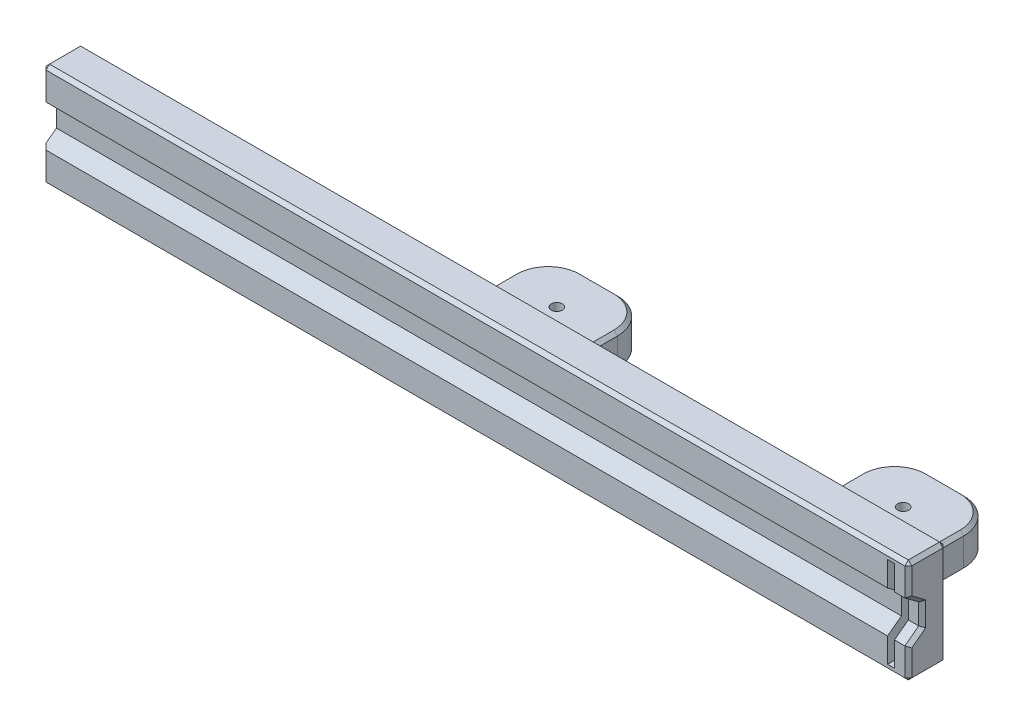
from build123d import *

# Parameters (mm, degrees)
SKETCH_1_W          = 250
SKETCH_1_H          = 30
EXTRUDE_1_DEPTH     = 11
SKETCH_4_W          = 15
SKETCH_4_H          = 5
EXTRUDE_2_DEPTH     = 25
CUT_EXTRUDE_2_DEPTH = 251
CUT_EXTRUDE_3_DEPTH = 21
SKETCH_11_W         = 30
SKETCH_11_H         = 10
EXTRUDE_4_DEPTH     = 25
SKETCH_12_R         = 1.6
CUT_EXTRUDE_5_DEPTH = 21
FILLET_1_R          = 10
SKETCH_13_W         = 2
SKETCH_13_H         = 26.2
CUT_EXTRUDE_6_DEPTH = 37
CHAMFER_1_SIZE      = 1


with BuildPart() as part:
    # 草圖1 → 填料-伸長1 (new body)
    with BuildSketch(Plane.XY):
        with Locations((125, 15)):
            Rectangle(SKETCH_1_W, SKETCH_1_H)
    extrude(amount=EXTRUDE_1_DEPTH)

    # 草圖4 → 填料-伸長2 (add)
    with BuildSketch(Plane(origin=(0, 0, 0), x_dir=(-1, 0, 0), z_dir=(0, 0, -1))):
        with Locations((-132.5, 12.5)):
            Rectangle(SKETCH_4_W, SKETCH_4_H)
        with Locations((-132.5, 17.5)):
            Rectangle(SKETCH_4_W, SKETCH_4_H)
        with Locations((-117.5, 17.5)):
            Rectangle(SKETCH_4_W, SKETCH_4_H)
        with Locations((-117.5, 12.5)):
            Rectangle(SKETCH_4_W, SKETCH_4_H)
    extrude(amount=EXTRUDE_2_DEPTH)

    # 草圖5 → 除料-伸長2 (cut, through all)
    with BuildSketch(Plane(origin=(250, 0, 0), x_dir=(0, 0, -1), z_dir=(1, 0, 0))):
        Polygon((-11, 15), (-7, 15), (-7, 18), (-11, 21), align=None)
        Polygon((-7, 12), (-7, 15), (-11, 15), (-11, 9), align=None)
    extrude(amount=-CUT_EXTRUDE_2_DEPTH, mode=Mode.SUBTRACT)

    # 草圖6 → 除料-伸長3 (cut, through all)
    with BuildSketch(Plane.XZ.offset(-10)):
        with BuildLine():
            ThreePointArc((126.6, -12.5), (126.13137085, -11.36862915), (125, -10.9))
            Line((125, -10.9), (125, -12.5))
            Line((125, -12.5), (126.6, -12.5))
        make_face()
        with BuildLine():
            Line((125, -12.5), (125, -10.9))
            ThreePointArc((125, -10.9), (123.86862915, -11.36862915), (123.4, -12.5))
            Line((123.4, -12.5), (125, -12.5))
        make_face()
        with BuildLine():
            Line((126.6, -12.5), (125, -12.5))
            Line((125, -12.5), (125, -14.1))
            ThreePointArc((125, -14.1), (126.13137085, -13.63137085), (126.6, -12.5))
        make_face()
        with BuildLine():
            Line((125, -14.1), (125, -12.5))
            Line((125, -12.5), (123.4, -12.5))
            ThreePointArc((123.4, -12.5), (123.86862915, -13.63137085), (125, -14.1))
        make_face()
    extrude(amount=-CUT_EXTRUDE_3_DEPTH, mode=Mode.SUBTRACT)

    # 草圖11 → 填料-伸長4 (add)
    with BuildSketch(Plane(origin=(0, 0, 0), x_dir=(-1, 0, 0), z_dir=(0, 0, -1))):
        with Locations((-225, 15)):
            Rectangle(SKETCH_11_W, SKETCH_11_H)
    extrude(amount=EXTRUDE_4_DEPTH)

    # 草圖12 → 除料-伸長5 (cut, through all)
    with BuildSketch(Plane(origin=(0, 20, 0), x_dir=(1, 0, 0), z_dir=(0, 1, 0))):
        with Locations((225, 12.5)):
            Circle(SKETCH_12_R)
    extrude(amount=-CUT_EXTRUDE_5_DEPTH, mode=Mode.SUBTRACT)

    # 圓角1
    fillet_1_edges = [part.edges().sort_by_distance(p)[0] for p in [
        (110, 15, -25),
        (140, 15, -25),
        (240, 15, -25),
        (210, 15, -25),
    ]]
    fillet(fillet_1_edges, radius=FILLET_1_R)

    # 草圖13 → 除料-伸長6 (cut, through all)
    with BuildSketch(Plane.XY.offset(11)):
        with Locations((245, 15)):
            Rectangle(SKETCH_13_W, SKETCH_13_H)
    extrude(amount=-CUT_EXTRUDE_6_DEPTH, mode=Mode.SUBTRACT)

    # 導角1
    chamfer_1_edges = [part.edges().sort_by_distance(p)[0] for p in [
        (250, 4.5, 11),
        (125, 30, 11),
        (110, 15, 0),
        (140, 15, 0),
        (125, 10, 0),
        (125, 20, 0),
        (0, 4.5, 11),
        (250, 25.5, 11),
        (250, 10.5, 9),
        (250, 15, 7),
        (250, 19.5, 9),
        (0, 25.5, 11),
        (125, 30, 0),
        (250, 15, 0),
        (125, 0, 0),
        (225, 10, 0),
        (210, 15, 0),
        (0, 15, 0),
        (240, 15, 0),
        (225, 20, 0),
        (125, 0, 11),
        (125, 20, -25),
        (125, 10, -25),
        (0, 30, 5.5),
        (250, 30, 5.5),
        (140, 20, -7.5),
        (110, 20, -7.5),
        (137.071067812, 20, -22.071067812),
        (250, 0, 5.5),
        (112.928932188, 20, -22.071067812),
        (110, 10, -7.5),
        (0, 0, 5.5),
        (140, 10, -7.5),
        (137.071067812, 10, -22.071067812),
        (112.928932188, 10, -22.071067812),
        (225, 10, -25),
        (225, 20, -25),
        (240, 20, -7.5),
        (210, 20, -7.5),
        (237.071067812, 20, -22.071067812),
        (212.928932188, 20, -22.071067812),
        (210, 10, -7.5),
        (240, 10, -7.5),
        (237.071067812, 10, -22.071067812),
        (212.928932188, 10, -22.071067812),
    ]]
    chamfer(chamfer_1_edges, length=CHAMFER_1_SIZE)


solid = part.part
